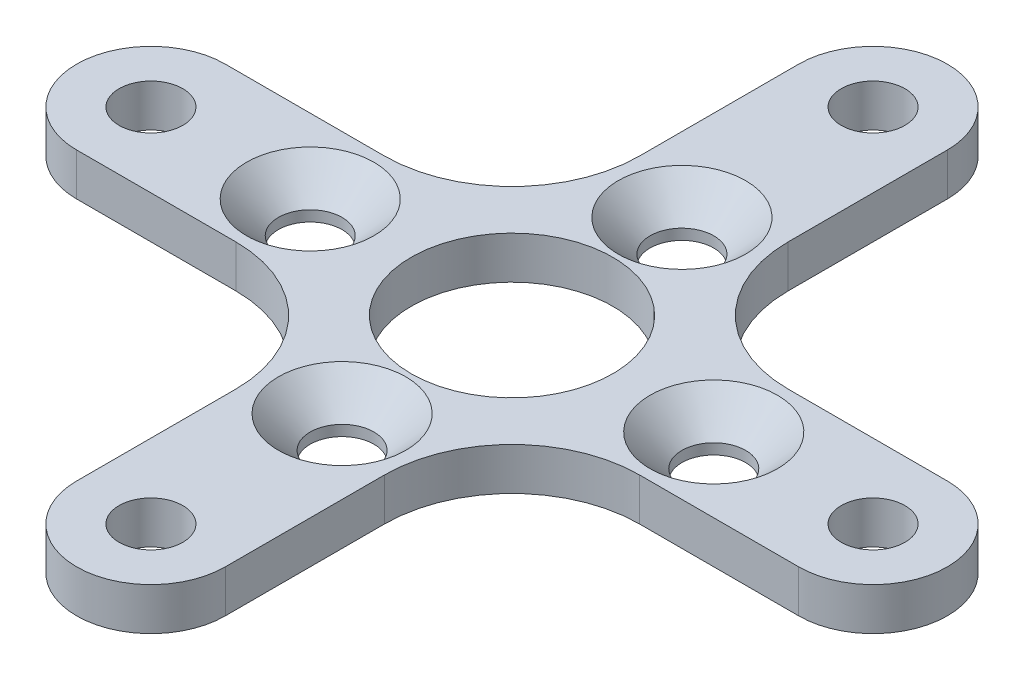
from build123d import *

# Parameters (mm, degrees)
SKETCH1_R           = 4.75
SKETCH1_R_2         = 1.5
BOSS_EXTRUDE1_DEPTH = 2
CHAMFER1_SIZE       = 1.5


with BuildPart() as part:
    # Sketch1 → Boss-Extrude1 (new body)
    with BuildSketch(Plane(origin=(0, 0, 0), x_dir=(1, 0, 0), z_dir=(0, 1, 0))):
        with BuildLine():
            Line((3.5, 17), (3.5, 9.5))
            ThreePointArc((3.5, 9.5), (5.257359313, 5.257359313), (9.5, 3.5))
            Line((9.5, 3.5), (17, 3.5))
            ThreePointArc((17, 3.5), (20.5, 0), (17, -3.5))
            Line((17, -3.5), (9.5, -3.5))
            ThreePointArc((9.5, -3.5), (5.257359313, -5.257359313), (3.5, -9.5))
            Line((3.5, -9.5), (3.5, -17))
            ThreePointArc((3.5, -17), (0, -20.5), (-3.5, -17))
            Line((-3.5, -17), (-3.5, -9.5))
            ThreePointArc((-3.5, -9.5), (-5.257359313, -5.257359313), (-9.5, -3.5))
            Line((-9.5, -3.5), (-17, -3.5))
            ThreePointArc((-17, -3.5), (-20.5, 0), (-17, 3.5))
            Line((-17, 3.5), (-9.5, 3.5))
            ThreePointArc((-9.5, 3.5), (-5.257359313, 5.257359313), (-3.5, 9.5))
            Line((-3.5, 9.5), (-3.5, 17))
            ThreePointArc((-3.5, 17), (0, 20.5), (3.5, 17))
        make_face()
        Circle(SKETCH1_R, mode=Mode.SUBTRACT)
        with Locations((0, 8)):
            Circle(SKETCH1_R_2, mode=Mode.SUBTRACT)
        with Locations((0, 17)):
            Circle(SKETCH1_R_2, mode=Mode.SUBTRACT)
        with Locations((17, 0)):
            Circle(SKETCH1_R_2, mode=Mode.SUBTRACT)
        with Locations((9.5, 0)):
            Circle(SKETCH1_R_2, mode=Mode.SUBTRACT)
        with Locations((0, -17)):
            Circle(SKETCH1_R_2, mode=Mode.SUBTRACT)
        with Locations((0, -8)):
            Circle(SKETCH1_R_2, mode=Mode.SUBTRACT)
        with Locations((-17, 0)):
            Circle(SKETCH1_R_2, mode=Mode.SUBTRACT)
        with Locations((-9.5, 0)):
            Circle(SKETCH1_R_2, mode=Mode.SUBTRACT)
    extrude(amount=BOSS_EXTRUDE1_DEPTH)

    # Chamfer1
    chamfer1_edges = [part.edges().sort_by_distance(p)[0] for p in [
        (-11, 2, 0),
        (-1.5, 2, 8),
        (8, 2, 0),
        (-1.5, 2, -8),
    ]]
    chamfer(chamfer1_edges, length=CHAMFER1_SIZE)


solid = part.part
